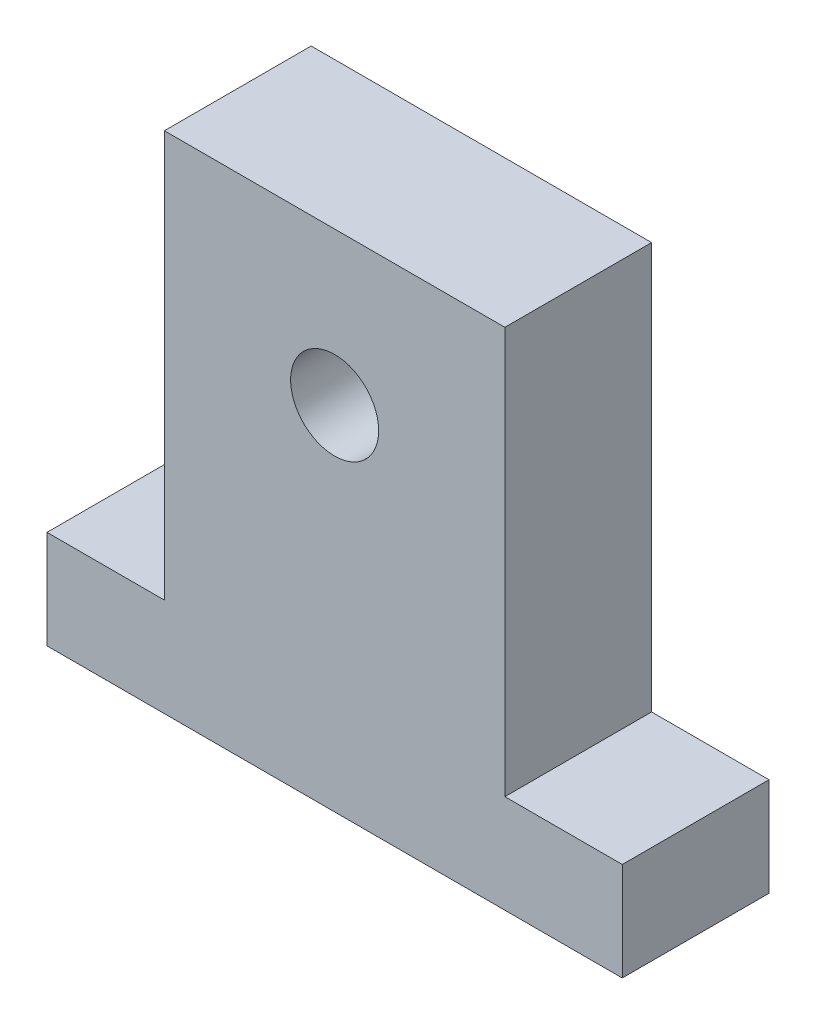
from build123d import *

# Parameters (mm, degrees)
CROQUIS1_R              = 3
SALIENTE_EXTRUIR1_DEPTH = 10


with BuildPart() as part:
    # Croquis1 → Saliente-Extruir1 (new body)
    with BuildSketch(Plane.XY):
        Polygon((-19.6, 0), (-19.6, 6.7), (-11.6, 6.7), (-11.6, 34.4), (11.6, 34.4), (11.6, 6.7), (19.6, 6.7), (19.6, 0), align=None)
        with Locations((0, 24)):
            Circle(CROQUIS1_R, mode=Mode.SUBTRACT)
    extrude(amount=SALIENTE_EXTRUIR1_DEPTH)


solid = part.part
